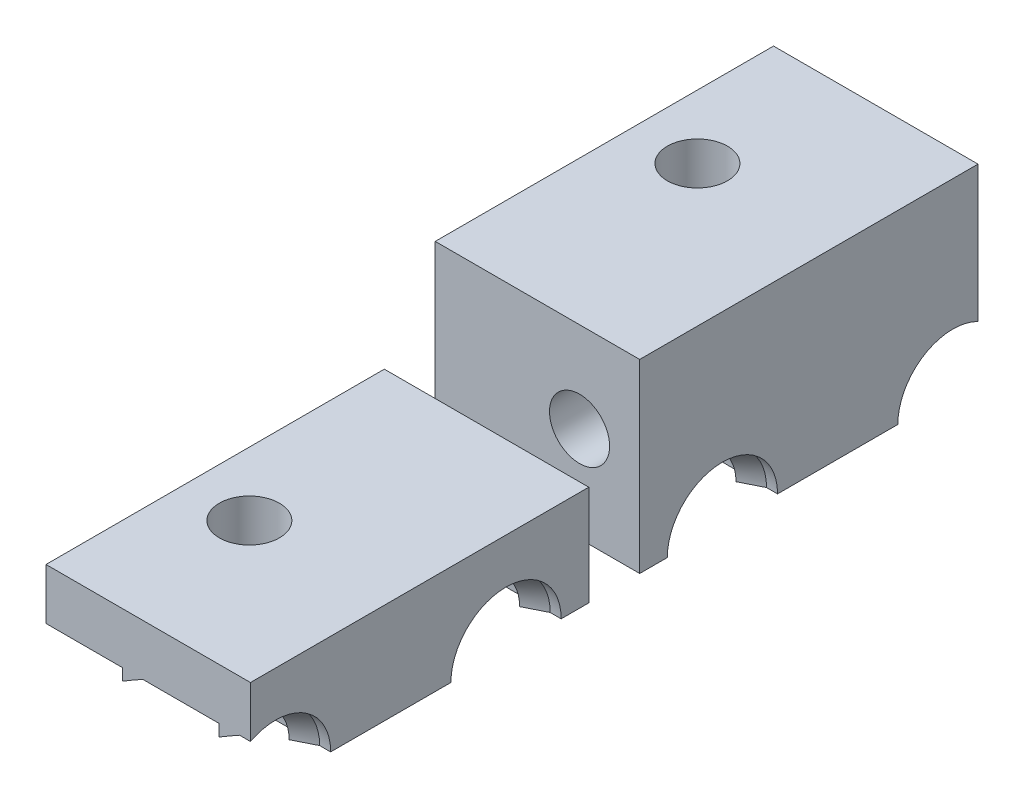
from build123d import *

# Parameters (mm, degrees)
REVOLVE1_ANGLE           = 180
BOSS_EXTRUDE1_DEPTH      = 9.25
BOSS_EXTRUDE1_DEPTH_BACK = 9.25
BOSS_EXTRUDE2_START      = 3.5
BOSS_EXTRUDE2_DEPTH      = 5.75
BOSS_EXTRUDE3_START      = -3.5
BOSS_EXTRUDE3_DEPTH      = 5.75
SKETCH14_W               = 2.5
SKETCH14_H               = 5
CUT_EXTRUDE10_DEPTH      = 17.487950145
SKETCH13_W               = 5.5
SKETCH13_H               = 2.75
CUT_EXTRUDE9_DEPTH       = 1.75
SKETCH15_W               = 12.7
SKETCH15_H               = 8
CUT_EXTRUDE11_DEPTH      = 25.836515456
SKETCH16_W               = 5.122625222
SKETCH16_H               = 5
CUT_EXTRUDE12_DEPTH      = 19.677593528
SKETCH22_W               = 2.5
SKETCH22_H               = 5
CUT_EXTRUDE17_DEPTH      = 22.705662381
SKETCH17_W               = 10.2
SKETCH17_H               = 16.877374778
BOSS_EXTRUDE4_DEPTH      = 4.25
SKETCH18_R               = 1.5
CUT_EXTRUDE13_DEPTH      = 28.275588567
SKETCH19_R               = 1.5
CUT_EXTRUDE14_DEPTH      = 27.141829157
SKETCH20_R               = 1.5
CUT_EXTRUDE16_DEPTH      = 24.804137104


with BuildPart() as part:
    # Sketch6 → Revolve1 (revolve)
    with BuildSketch(Plane(origin=(0, 0, 0), x_dir=(1, 0, 0), z_dir=(0, 1, 0))):
        Polygon((0, 5), (0, 2.75), (3.81, 2.75), (3.81, 2.242), (4.826, 2.75), (8.636, 2.75), (8.636, 2.242), (9.652, 2.75), (12.7, 2.75), (12.7, 5), align=None)
    revolve(axis=Axis((0, 0, 0), (1, 0, 0)), revolution_arc=REVOLVE1_ANGLE)

    # Sketch9 → Boss-Extrude1 (add, two sides: drawn at the far end of the back side and taken through both)
    with BuildSketch(Plane.XY.offset(-BOSS_EXTRUDE1_DEPTH_BACK)):
        Polygon((0, 5), (0, 3.25), (12.7, 2.75), (12.7, 5), align=None)
    extrude(amount=BOSS_EXTRUDE1_DEPTH + BOSS_EXTRUDE1_DEPTH_BACK)

    # Sketch9_3 → Boss-Extrude2 (add)
    with BuildSketch(Plane.XY.offset(BOSS_EXTRUDE2_START)):
        Polygon((0, 3.25), (0, 0), (12.7, 0), (12.7, 2.75), align=None)
    extrude(amount=BOSS_EXTRUDE2_DEPTH)

    # Sketch9_4 → Boss-Extrude3 (add)
    with BuildSketch(Plane.XY.offset(BOSS_EXTRUDE3_START)):
        Polygon((0, 3.25), (0, 0), (12.7, 0), (12.7, 2.75), align=None)
    extrude(amount=-BOSS_EXTRUDE3_DEPTH)

    # Sketch14 → Cut-Extrude10 (cut, through all)
    with BuildSketch(Plane.ZY):
        with Locations((-8, 2.5)):
            Rectangle(SKETCH14_W, SKETCH14_H)
    extrude(amount=-CUT_EXTRUDE10_DEPTH, mode=Mode.SUBTRACT)

    # Mirror4: part across plane


with BuildPart() as part_1:
    add(part.part)
    add(part.part.mirror(Plane.XY.offset(-5.75)))

    # Sketch13 → Cut-Extrude9 (cut)
    with BuildSketch(Plane.ZY):
        with Locations((0, 1.375)):
            Rectangle(SKETCH13_W, SKETCH13_H)
    extrude(amount=-CUT_EXTRUDE9_DEPTH, mode=Mode.SUBTRACT)

    # Sketch15 → Cut-Extrude11 (cut, through all)
    with BuildSketch(Plane(origin=(0, 5, 0), x_dir=(1, 0, 0), z_dir=(0, 1, 0))):
        with Locations((6.35, 16.75)):
            Rectangle(SKETCH15_W, SKETCH15_H)
    extrude(amount=-CUT_EXTRUDE11_DEPTH, mode=Mode.SUBTRACT)

    # Sketch16 → Cut-Extrude12 (cut, through all)
    with BuildSketch(Plane.ZY):
        with Locations((6.688687389, 2.5)):
            Rectangle(SKETCH16_W, SKETCH16_H)
    extrude(amount=-CUT_EXTRUDE12_DEPTH, mode=Mode.SUBTRACT)

    # Sketch22 → Cut-Extrude17 (cut, through all)
    with BuildSketch(Plane.XY.offset(4.127374778)):
        with Locations((11.45, 2.5)):
            Rectangle(SKETCH22_W, SKETCH22_H)
    extrude(amount=-CUT_EXTRUDE17_DEPTH, mode=Mode.SUBTRACT)


with BuildPart() as body_2:
    # Mirror8: mirrored copy
    add(part_1.part.mirror(Plane.XY.offset(5.397374778)))

    # Sketch19 → Cut-Extrude14 (cut, through all)
    with BuildSketch(Plane(origin=(0, 5, 0), x_dir=(1, 0, 0), z_dir=(0, 1, 0))):
        with Locations((3.175, -16.573374778)):
            Circle(SKETCH19_R)
    extrude(amount=-CUT_EXTRUDE14_DEPTH, mode=Mode.SUBTRACT)


with BuildPart() as part_2:
    add(part_1.part)

    # Sketch17 → Boss-Extrude4 (add)
    with BuildSketch(Plane(origin=(0, 5, 0), x_dir=(1, 0, 0), z_dir=(0, 1, 0))):
        with Locations((5.1, 4.311312611)):
            Rectangle(SKETCH17_W, SKETCH17_H)
    extrude(amount=BOSS_EXTRUDE4_DEPTH)

    # Sketch18 → Cut-Extrude13 (cut, through all)
    with BuildSketch(Plane(origin=(0, 9.25, 0), x_dir=(1, 0, 0), z_dir=(0, 1, 0))):
        with Locations((3.175, 5.778625222)):
            Circle(SKETCH18_R)
    extrude(amount=-CUT_EXTRUDE13_DEPTH, mode=Mode.SUBTRACT)

    # Sketch20 → Cut-Extrude16 (cut, through all)
    with BuildSketch(Plane.XY.offset(4.127374778)):
        with Locations((7.2, 4.75)):
            Circle(SKETCH20_R)
    extrude(amount=-CUT_EXTRUDE16_DEPTH, mode=Mode.SUBTRACT)


solid = Compound([body_2.part, part_2.part])
